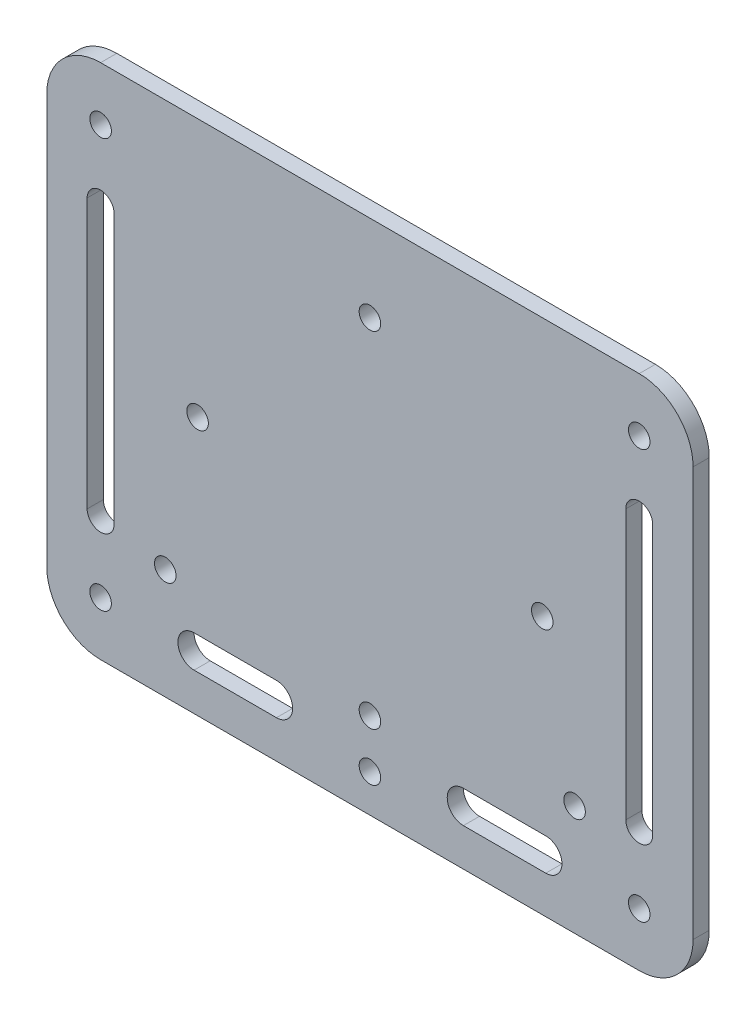
from build123d import *

# Parameters (mm, degrees)
SKETCH1_R           = 2
BOSS_EXTRUDE1_DEPTH = 3


with BuildPart() as part:
    # Sketch1 → Boss-Extrude1 (new body)
    with BuildSketch(Plane.XY):
        with BuildLine():
            Line((-50, 48), (50, 48))
            ThreePointArc((50, 48), (57.071067812, 45.071067812), (60, 38))
            Line((60, 38), (60, -38))
            ThreePointArc((60, -38), (57.071067812, -45.071067812), (50, -48))
            Line((50, -48), (-50, -48))
            ThreePointArc((-50, -48), (-57.071067812, -45.071067812), (-60, -38))
            Line((-60, -38), (-60, 38))
            ThreePointArc((-60, 38), (-57.071067812, 45.071067812), (-50, 48))
        make_face()
        with Locations((0, 32)):
            Circle(SKETCH1_R, mode=Mode.SUBTRACT)
        with Locations((0, -32)):
            Circle(SKETCH1_R, mode=Mode.SUBTRACT)
        with Locations((32, 0)):
            Circle(SKETCH1_R, mode=Mode.SUBTRACT)
        with Locations((-32, 0)):
            Circle(SKETCH1_R, mode=Mode.SUBTRACT)
        with Locations((-50, 38)):
            Circle(SKETCH1_R, mode=Mode.SUBTRACT)
        with Locations((50, 38)):
            Circle(SKETCH1_R, mode=Mode.SUBTRACT)
        with Locations((50, -38)):
            Circle(SKETCH1_R, mode=Mode.SUBTRACT)
        with Locations((-50, -38)):
            Circle(SKETCH1_R, mode=Mode.SUBTRACT)
        with Locations((-38, -27.5)):
            Circle(SKETCH1_R, mode=Mode.SUBTRACT)
        with Locations((38, -27.5)):
            Circle(SKETCH1_R, mode=Mode.SUBTRACT)
        with Locations((0, -41)):
            Circle(SKETCH1_R, mode=Mode.SUBTRACT)
        with BuildLine():
            Line((17.35191045, -35), (32.64808955, -35))
            ThreePointArc((32.64808955, -35), (35.64808955, -38), (32.64808955, -41))
            Line((32.64808955, -41), (17.35191045, -41))
            ThreePointArc((17.35191045, -41), (14.35191045, -38), (17.35191045, -35))
        make_face(mode=Mode.SUBTRACT)
        with BuildLine():
            Line((52.5, 25), (52.5, -25))
            ThreePointArc((52.5, -25), (50, -27.5), (47.5, -25))
            Line((47.5, -25), (47.5, 25))
            ThreePointArc((47.5, 25), (50, 27.5), (52.5, 25))
        make_face(mode=Mode.SUBTRACT)
        with BuildLine():
            Line((-47.5, 25), (-47.5, -25))
            ThreePointArc((-47.5, -25), (-50, -27.5), (-52.5, -25))
            Line((-52.5, -25), (-52.5, 25))
            ThreePointArc((-52.5, 25), (-50, 27.5), (-47.5, 25))
        make_face(mode=Mode.SUBTRACT)
        with BuildLine():
            Line((-32.64808955, -35), (-17.35191045, -35))
            ThreePointArc((-17.35191045, -35), (-14.35191045, -38), (-17.35191045, -41))
            Line((-17.35191045, -41), (-32.64808955, -41))
            ThreePointArc((-32.64808955, -41), (-35.64808955, -38), (-32.64808955, -35))
        make_face(mode=Mode.SUBTRACT)
    extrude(amount=BOSS_EXTRUDE1_DEPTH)


solid = part.part
